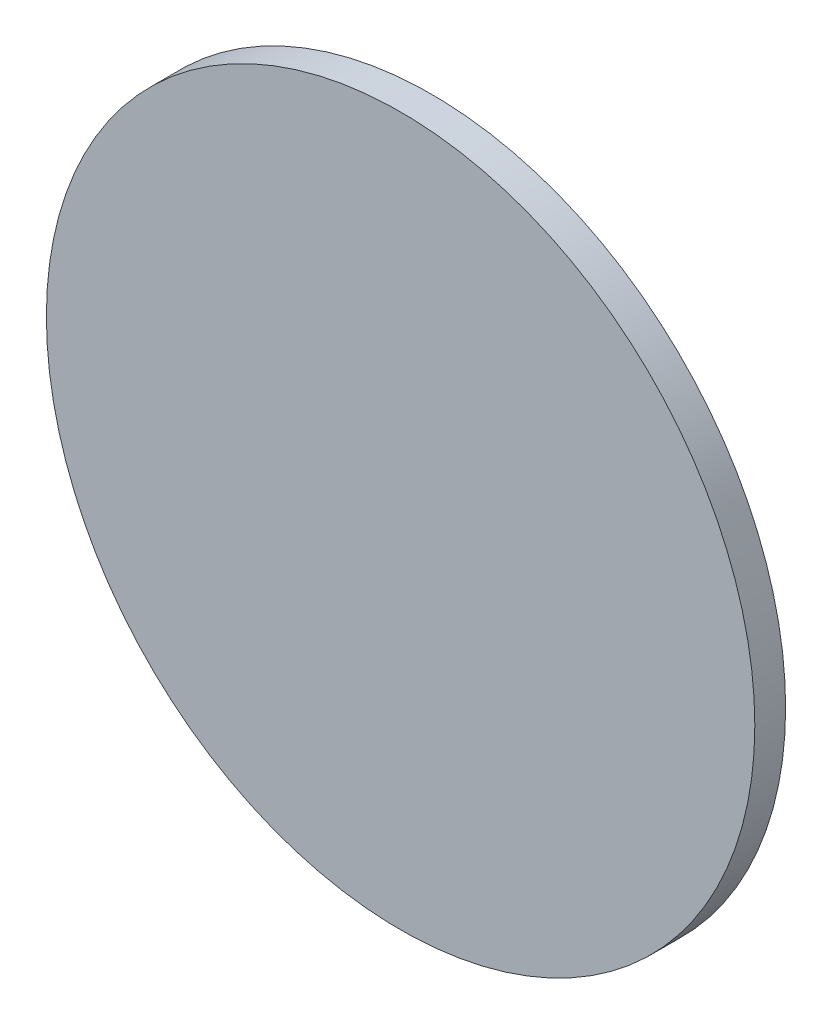
from build123d import *

# Parameters (mm, degrees)
SKETCH1_R           = 23
BOSS_EXTRUDE1_DEPTH = 2


with BuildPart() as part:
    # Sketch1 → Boss-Extrude1 (new body)
    with BuildSketch(Plane.XY):
        Circle(SKETCH1_R)
    extrude(amount=BOSS_EXTRUDE1_DEPTH)


solid = part.part
